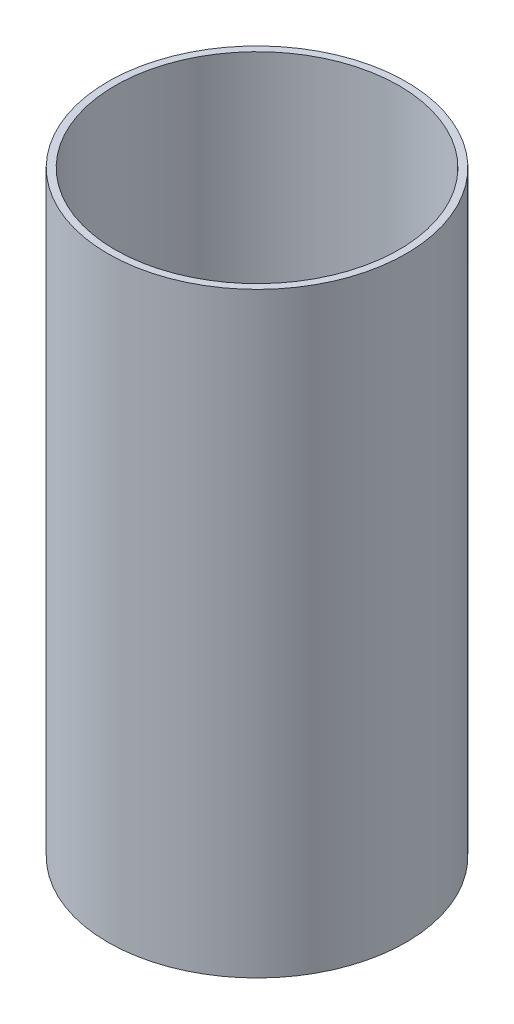
from build123d import *

# Parameters (mm, degrees)
SKETCH1_R           = 63.5
SKETCH1_R_2         = 60.5028
BOSS_EXTRUDE1_DEPTH = 254


with BuildPart() as part:
    # Sketch1 → Boss-Extrude1 (new body)
    with BuildSketch(Plane(origin=(0, 0, 0), x_dir=(1, 0, 0), z_dir=(0, 1, 0))):
        Circle(SKETCH1_R)
        Circle(SKETCH1_R_2, mode=Mode.SUBTRACT)
    extrude(amount=BOSS_EXTRUDE1_DEPTH)


solid = part.part
